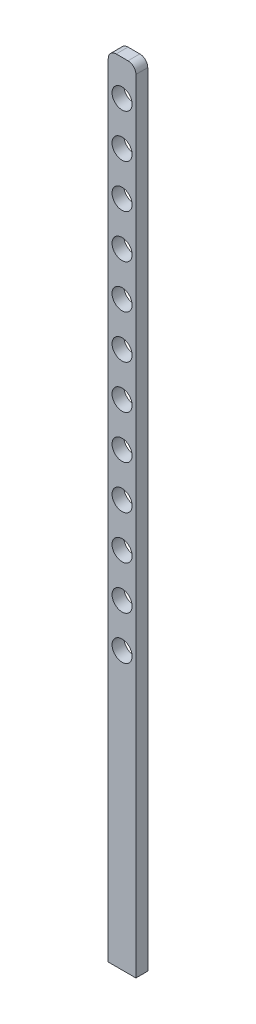
from build123d import *

# Parameters (mm, degrees)
SKETCH1_W           = 35
SKETCH1_H           = 1000
BOSS_EXTRUDE1_DEPTH = 7.5
SKETCH2_R           = 12.7
CUT_EXTRUDE1_DEPTH  = 8.5
LPATTERN1_COUNT     = 12
LPATTERN1_PITCH     = 55
FILLET1_R           = 10


with BuildPart() as part:
    # Sketch1 → Boss-Extrude1 (new body, symmetric)
    with BuildSketch(Plane.XY):
        Rectangle(SKETCH1_W, SKETCH1_H)
    extrude(amount=BOSS_EXTRUDE1_DEPTH, both=True)

    # Sketch2 → Cut-Extrude1 (cut, symmetric)
    with BuildSketch(Plane.XY):
        with Locations((0, -150)):
            Circle(SKETCH2_R)
    cut_extrude1 = extrude(amount=CUT_EXTRUDE1_DEPTH, both=True, mode=Mode.SUBTRACT)

    # LPattern1: Cut-Extrude1 ×12
    with Locations(*[(0, i * LPATTERN1_PITCH, 0) for i in range(1, LPATTERN1_COUNT)]):
        add(cut_extrude1, mode=Mode.SUBTRACT)

    # Fillet1
    fillet1_edges = [part.edges().sort_by_distance(p)[0] for p in [
        (-17.5, 500, 0),
        (17.5, 500, 0),
    ]]
    fillet(fillet1_edges, radius=FILLET1_R)


solid = part.part
